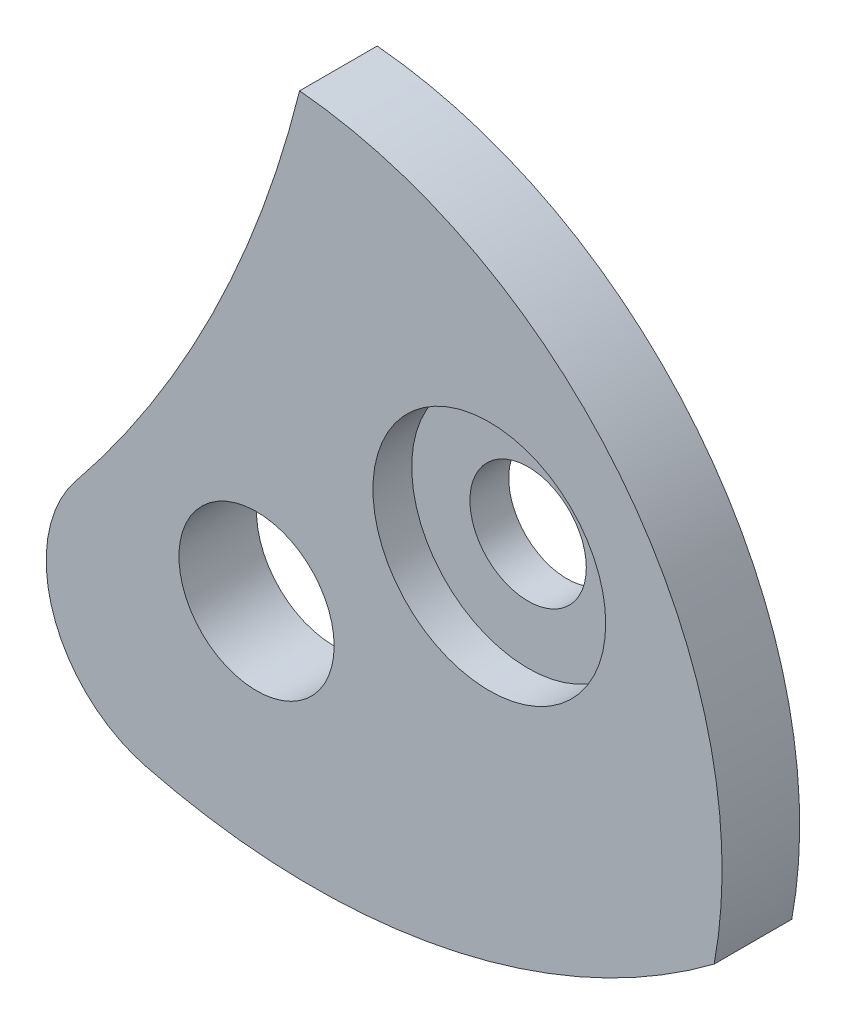
from build123d import *

# Parameters (mm, degrees)
CROQUIS1_R                 = 0.5
SALIENTE_EXTRUIR1_DEPTH    = 0.5
CROQUIS2_R                 = 0.75
CORTAR_EXTRUIR1_DEPTH      = 0.25
TALADRO_ROSCADO_M1X0_251_D = 0.75


with BuildPart() as part:
    # Croquis1 → Saliente-Extruir1 (new body)
    with BuildSketch(Plane.XY):
        with BuildLine():
            ThreePointArc((2.949014501, -0.550739024), (2.394136779, 1.807791217), (0.277602425, 2.987128537))
            ThreePointArc((0.277602425, 2.987128537), (-0.285523417, 1.458472772), (-1.165441148, 0.087471697))
            ThreePointArc((-1.165441148, 0.087471697), (-1.311898812, -0.719273217), (-0.712369976, -1.278605298))
            ThreePointArc((-0.712369976, -1.278605298), (1.201069025, -1.330913059), (2.949014501, -0.550739024))
        make_face()
        Circle(CROQUIS1_R, mode=Mode.SUBTRACT)
    extrude(amount=SALIENTE_EXTRUIR1_DEPTH)

    # Croquis2 → Cortar-Extruir1 (cut)
    with BuildSketch(Plane.XY.offset(0.5)):
        with Locations((1.5, 1)):
            Circle(CROQUIS2_R)
    extrude(amount=-CORTAR_EXTRUIR1_DEPTH, mode=Mode.SUBTRACT)

    # Taladro roscado M1x0.251 (through all)
    with Locations(Plane.XY.offset(0.25)):
        with Locations((1.5, 1)):
            Hole(TALADRO_ROSCADO_M1X0_251_D / 2)


solid = part.part
